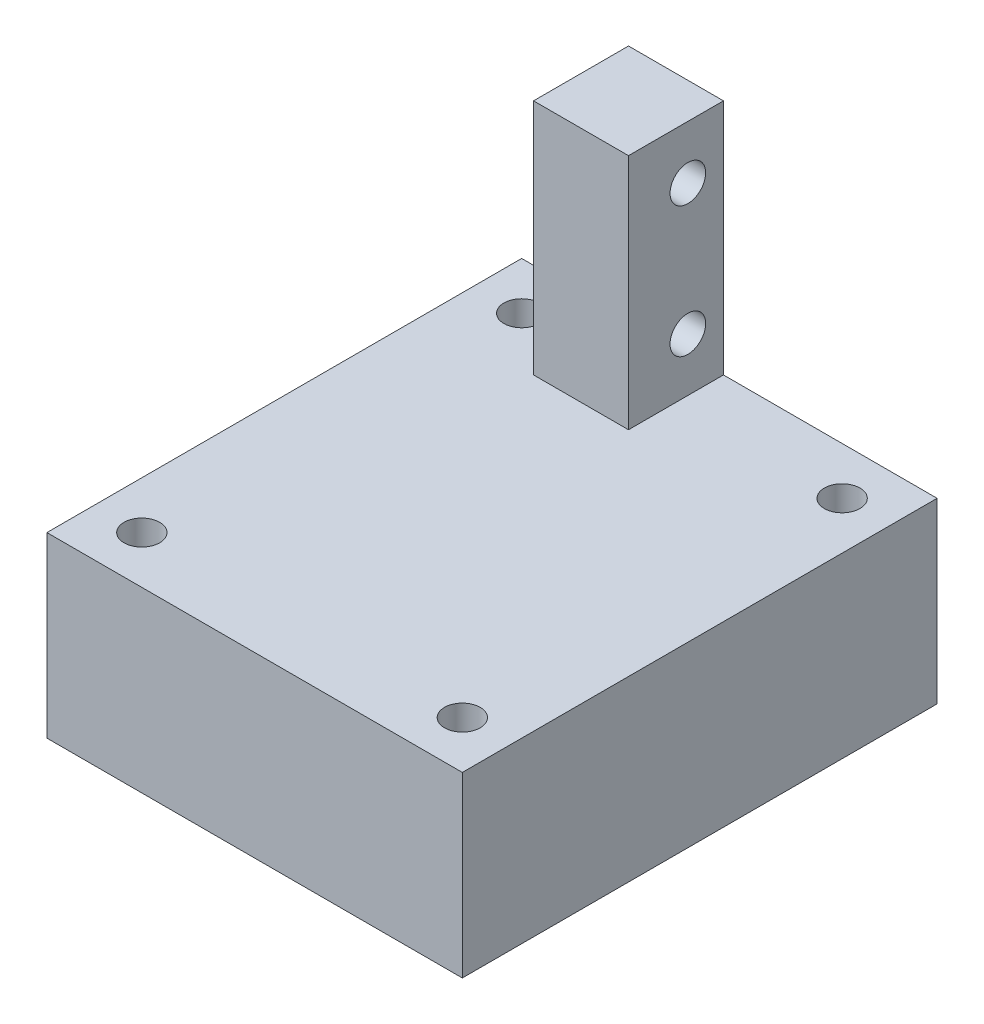
from build123d import *

# Parameters (mm, degrees)
SKETCH_1_W          = 35
SKETCH_1_H          = 40
EXTRUDE_1_DEPTH     = 15
SKETCH_4_R          = 1.5
CUT_EXTRUDE_1_DEPTH = 25
SKETCH_5_W          = 8
SKETCH_5_H          = 8
EXTRUDE_2_DEPTH     = 20
SKETCH_6_R          = 1.5
CUT_EXTRUDE_2_DEPTH = 20


with BuildPart() as part:
    # Эскиз1 → Бобышка-Вытянуть1 (new body)
    with BuildSketch(Plane(origin=(0, 0, 0), x_dir=(1, 0, 0), z_dir=(0, 1, 0))):
        Rectangle(SKETCH_1_W, SKETCH_1_H)
    extrude(amount=EXTRUDE_1_DEPTH)

    # Эскиз4 → Вырез-Вытянуть1 (cut)
    with BuildSketch(Plane(origin=(0, 15, 0), x_dir=(1, 0, 0), z_dir=(0, 1, 0))):
        with BuildLine():
            ThreePointArc((-12, 16), (-14.560660172, 17.060660172), (-13.5, 14.5))
            Line((-13.5, 14.5), (-13.5, 16))
            Line((-13.5, 16), (-12, 16))
        make_face()
        with BuildLine():
            Line((-13.5, 16), (-13.5, 14.5))
            ThreePointArc((-13.5, 14.5), (-12.439339828, 14.939339828), (-12, 16))
            Line((-12, 16), (-13.5, 16))
        make_face()
        with BuildLine():
            ThreePointArc((15, -16), (14.560660172, -14.939339828), (13.5, -14.5))
            Line((13.5, -14.5), (13.5, -16))
            Line((13.5, -16), (12, -16))
            ThreePointArc((12, -16), (13.5, -17.5), (15, -16))
        make_face()
        with BuildLine():
            Line((13.5, -16), (13.5, -14.5))
            ThreePointArc((13.5, -14.5), (12.439339828, -14.939339828), (12, -16))
            Line((12, -16), (13.5, -16))
        make_face()
        with BuildLine():
            ThreePointArc((12, 16), (12.439339828, 14.939339828), (13.5, 14.5))
            Line((13.5, 14.5), (13.5, 16))
            Line((13.5, 16), (12, 16))
        make_face()
        with BuildLine():
            Line((13.5, 16), (13.5, 14.5))
            ThreePointArc((13.5, 14.5), (14.560660172, 14.939339828), (15, 16))
            ThreePointArc((15, 16), (13.5, 17.5), (12, 16))
            Line((12, 16), (13.5, 16))
        make_face()
        with Locations((-13.5, -16)):
            Circle(SKETCH_4_R)
    extrude(amount=-CUT_EXTRUDE_1_DEPTH, mode=Mode.SUBTRACT)

    # Эскиз5 → Бобышка-Вытянуть2 (add)
    with BuildSketch(Plane(origin=(0, 15, 0), x_dir=(1, 0, 0), z_dir=(0, 1, 0))):
        with Locations((-4.5, 16)):
            Rectangle(SKETCH_5_W, SKETCH_5_H)
    extrude(amount=EXTRUDE_2_DEPTH)

    # Эскиз6 → Вырез-Вытянуть2 (cut)
    with BuildSketch(Plane(origin=(-0.5, 0, 0), x_dir=(0, 0, -1), z_dir=(1, 0, 0))):
        with Locations((17, 30.5)):
            Circle(SKETCH_6_R)
        with Locations((17, 19.5)):
            Circle(SKETCH_6_R)
    extrude(amount=-CUT_EXTRUDE_2_DEPTH, mode=Mode.SUBTRACT)


solid = part.part
